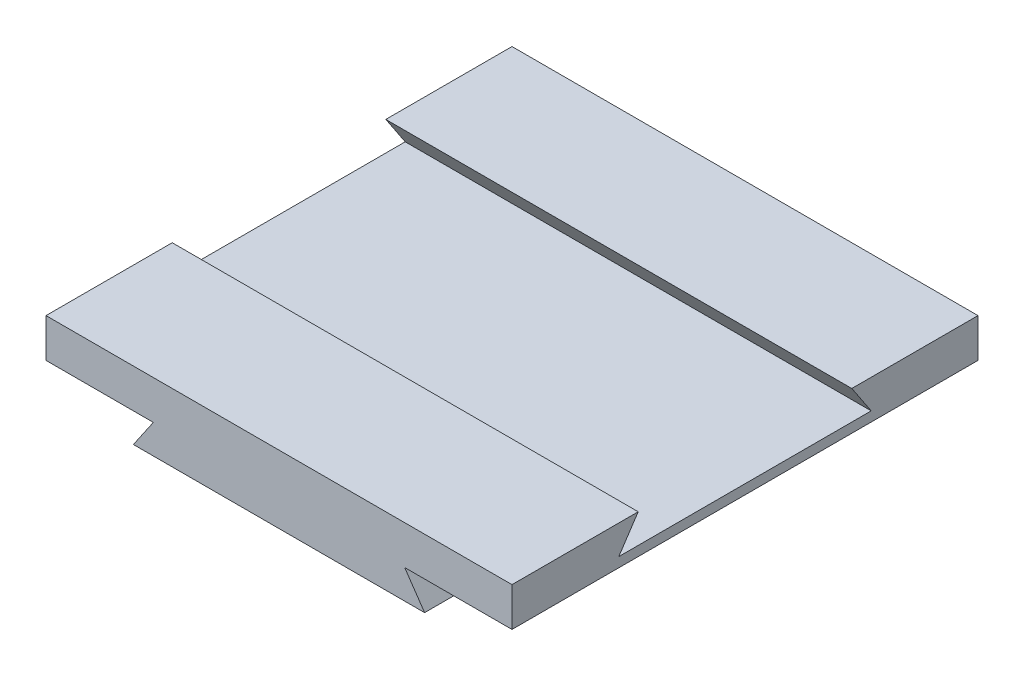
from build123d import *

# Parameters (mm, degrees)
EXTRUDE_1_DEPTH     = 240
CUT_EXTRUDE_1_DEPTH = 241


with BuildPart() as part:
    # Эскиз1 → Бобышка-Вытянуть1 (new body)
    with BuildSketch(Plane.XY):
        Polygon((0, 0), (75, 0), (64.72, 15), (120, 15), (120, 35), (0, 35), (-120, 35), (-120, 15), (-64.72, 15), (-75, 0), align=None)
    extrude(amount=EXTRUDE_1_DEPTH)

    # Эскиз2 → Вырез-Вытянуть1 (cut, through all)
    with BuildSketch(Plane.ZY.offset(120)):
        Polygon((65, 35), (175, 35), (185, 20), (55, 20), align=None)
    extrude(amount=-CUT_EXTRUDE_1_DEPTH, mode=Mode.SUBTRACT)


solid = part.part
